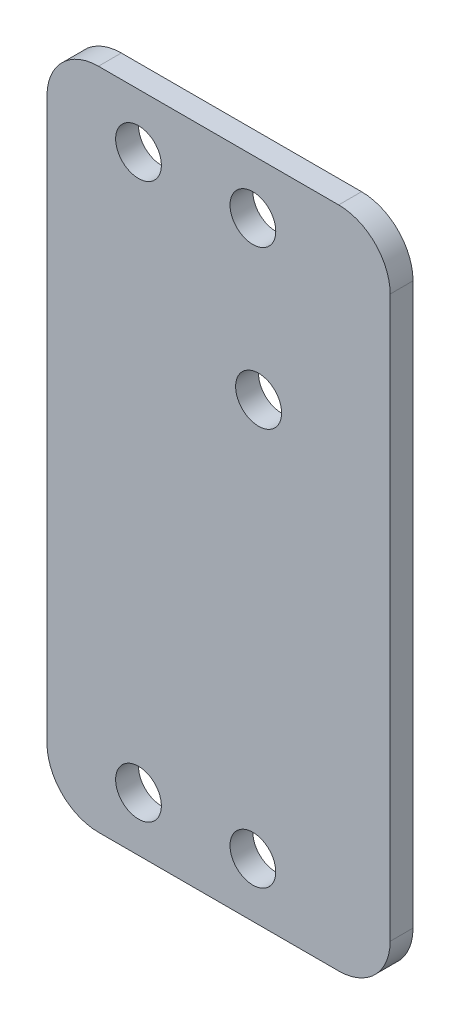
from build123d import *

# Parameters (mm, degrees)
SKETCH1_W           = 30
SKETCH1_H           = 58
SKETCH1_R           = 2
SKETCH1_R_2         = 2.01
BOSS_EXTRUDE1_DEPTH = 2
FILLET1_R           = 4.5


with BuildPart() as part:
    # Sketch1 → Boss-Extrude1 (new body)
    with BuildSketch(Plane.XY):
        Rectangle(SKETCH1_W, SKETCH1_H)
        with Locations((3, 24.25)):
            Circle(SKETCH1_R, mode=Mode.SUBTRACT)
        with Locations((-7, 24.25)):
            Circle(SKETCH1_R, mode=Mode.SUBTRACT)
        with Locations((-7, -24.25)):
            Circle(SKETCH1_R, mode=Mode.SUBTRACT)
        with Locations((3, -24.25)):
            Circle(SKETCH1_R, mode=Mode.SUBTRACT)
        with Locations((3.5, 10.75)):
            Circle(SKETCH1_R_2, mode=Mode.SUBTRACT)
    extrude(amount=BOSS_EXTRUDE1_DEPTH)

    # Fillet1
    fillet1_edges = [part.edges().sort_by_distance(p)[0] for p in [
        (-15, 29, 1),
        (15, 29, 1),
        (15, -29, 1),
        (-15, -29, 1),
    ]]
    fillet(fillet1_edges, radius=FILLET1_R)


solid = part.part
